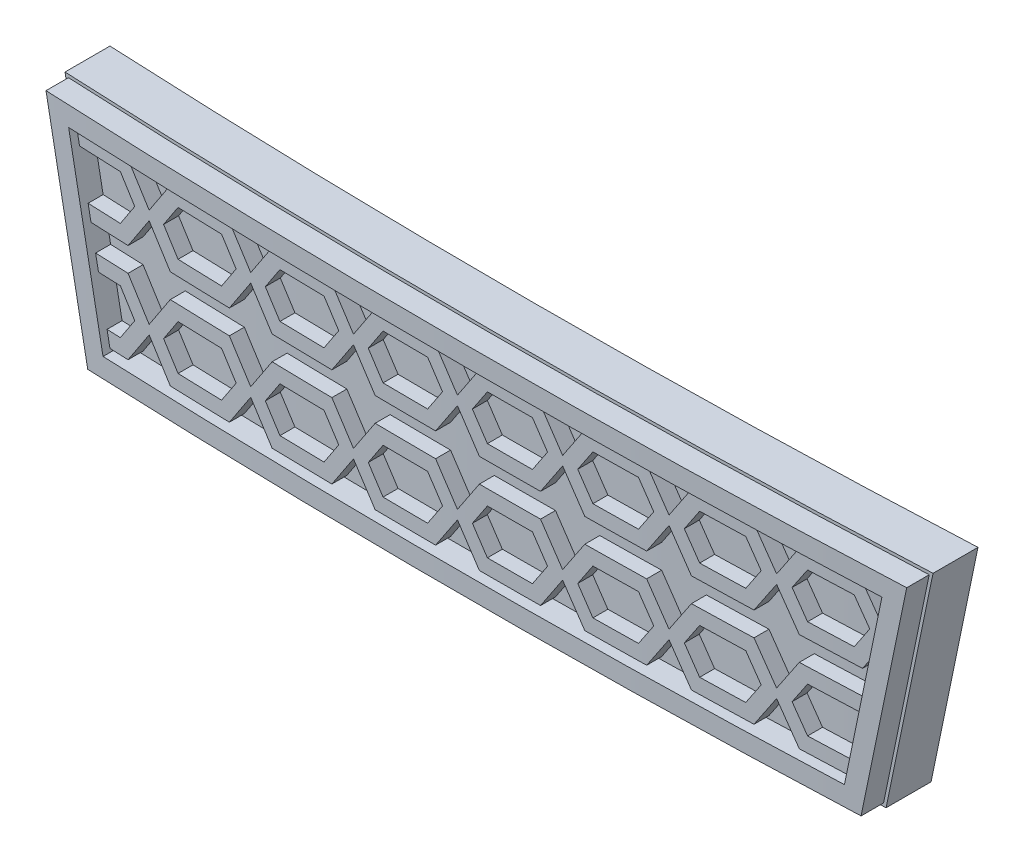
from build123d import *

# Parameters (mm, degrees)
BOSS_EXTRUDE1_DEPTH     = 25
SKETCH4_W               = 147
SKETCH4_H               = 25
CUT_EXTRUDE1_DEPTH      = 2.838054519
CUT_EXTRUDE1_DEPTH_BACK = 6.607602728
BOSS_EXTRUDE2_DEPTH     = 10
CUT_EXTRUDE2_DEPTH      = 16
CUT_EXTRUDE3_DEPTH      = 16
BOSS_EXTRUDE3_DEPTH     = 5
CUT_EXTRUDE4_DEPTH      = 16


with BuildPart() as part:
    # Sketch2 → Boss-Extrude1 (new body)
    with BuildSketch(Plane(origin=(0, 0, 0), x_dir=(1, 0, 0), z_dir=(0, 1, 0))):
        with BuildLine():
            Line((-73.115286629, 2.629690485), (-72.75191537, 5.607602728))
            ThreePointArc((-72.75191537, 5.607602728), (0.384713371, 1.161945481), (73.521342111, 5.607602728))
            Line((73.521342111, 5.607602728), (73.884713371, 2.629690485))
            ThreePointArc((73.884713371, 2.629690485), (0.384713371, -1.838054519), (-73.115286629, 2.629690485))
        make_face()
    extrude(amount=BOSS_EXTRUDE1_DEPTH)

    # Sketch4 → Cut-Extrude1 (cut, two sides)
    with BuildSketch(Plane.XY) as cut_extrude1_sk:
        with Locations((0.384713371, 12.5)):
            Rectangle(SKETCH4_W, SKETCH4_H)
        Polygon((-28.688823942, 19.998171544), (-25.688823942, 4.998171544), (26.311176058, 4.998171544), (29.311176058, 19.998171544), align=None, mode=Mode.SUBTRACT)
    extrude(amount=CUT_EXTRUDE1_DEPTH, mode=Mode.SUBTRACT)
    extrude(cut_extrude1_sk.sketch, amount=-CUT_EXTRUDE1_DEPTH_BACK, mode=Mode.SUBTRACT)

    # Sketch6 → Boss-Extrude2 (add, symmetric)
    with BuildSketch(Plane.XY):
        Polygon((25.88409597, 10.511300376), (26.037942124, 11.280531145), (25.761837756, 11.694687697), (21.691470239, 11.694687697), (20.226653997, 9.497463335), (18.761837756, 11.694687697), (14.691470239, 11.694687697), (13.226653997, 9.497463335), (11.761837756, 11.694687697), (7.691470239, 11.694687697), (6.226653997, 9.497463335), (4.761837756, 11.694687697), (0.691470239, 11.694687697), (-0.773346003, 9.497463335), (-2.238162244, 11.694687697), (-6.308529761, 11.694687697), (-7.773346003, 9.497463335), (-9.238162244, 11.694687697), (-13.308529761, 11.694687697), (-14.773346003, 9.497463335), (-16.238162244, 11.694687697), (-20.308529761, 11.694687697), (-21.773346003, 9.497463335), (-23.238162244, 11.694687697), (-25.498421319, 11.694687697), (-25.298421319, 10.694687697), (-23.773346003, 10.694687697), (-22.773346003, 9.194687697), (-23.773346003, 7.694687697), (-24.498421319, 7.694687697), (-24.698421319, 7.694687697), (-24.498421319, 6.694687697), (-23.238162244, 6.694687697), (-21.773346003, 8.89191206), (-20.308529761, 6.694687697), (-16.238162244, 6.694687697), (-14.773346003, 8.89191206), (-13.308529761, 6.694687697), (-9.238162244, 6.694687697), (-7.773346003, 8.89191206), (-6.308529761, 6.694687697), (-2.238162244, 6.694687697), (-0.773346003, 8.89191206), (0.691470239, 6.694687697), (4.761837756, 6.694687697), (6.226653997, 8.89191206), (7.691470239, 6.694687697), (11.761837756, 6.694687697), (13.226653997, 8.89191206), (14.691470239, 6.694687697), (18.761837756, 6.694687697), (20.226653997, 8.89191206), (21.691470239, 6.694687697), (25.120773434, 6.694687697), (25.370773434, 7.944687697), (25.120773434, 7.694687697), (22.226653997, 7.694687697), (21.226653997, 9.194687697), (22.226653997, 10.694687697), (25.761837756, 10.694687697), align=None)
        Polygon((18.226653997, 10.694687697), (19.226653997, 9.194687697), (18.226653997, 7.694687697), (15.226653997, 7.694687697), (14.226653997, 9.194687697), (15.226653997, 10.694687697), align=None, mode=Mode.SUBTRACT)
        Polygon((11.226653997, 10.694687697), (12.226653997, 9.194687697), (11.226653997, 7.694687697), (8.226653997, 7.694687697), (7.226653997, 9.194687697), (8.226653997, 10.694687697), align=None, mode=Mode.SUBTRACT)
        Polygon((4.226653997, 10.694687697), (5.226653997, 9.194687697), (4.226653997, 7.694687697), (1.226653997, 7.694687697), (0.226653997, 9.194687697), (1.226653997, 10.694687697), align=None, mode=Mode.SUBTRACT)
        Polygon((-2.773346003, 10.694687697), (-1.773346003, 9.194687697), (-2.773346003, 7.694687697), (-5.773346003, 7.694687697), (-6.773346003, 9.194687697), (-5.773346003, 10.694687697), align=None, mode=Mode.SUBTRACT)
        Polygon((-9.773346003, 10.694687697), (-8.773346003, 9.194687697), (-9.773346003, 7.694687697), (-12.773346003, 7.694687697), (-13.773346003, 9.194687697), (-12.773346003, 10.694687697), align=None, mode=Mode.SUBTRACT)
        Polygon((-16.773346003, 10.694687697), (-15.773346003, 9.194687697), (-16.773346003, 7.694687697), (-19.773346003, 7.694687697), (-20.773346003, 9.194687697), (-19.773346003, 10.694687697), align=None, mode=Mode.SUBTRACT)
        Polygon((-26.819814858, 18.30165539), (-26.619814858, 17.30165539), (-23.773346003, 17.30165539), (-22.773346003, 15.80165539), (-23.773346003, 14.30165539), (-25.819814858, 14.30165539), (-26.019814858, 14.30165539), (-25.819814858, 13.30165539), (-23.238162244, 13.30165539), (-21.773346003, 15.498879753), (-20.308529761, 13.30165539), (-16.238162244, 13.30165539), (-14.773346003, 15.498879753), (-13.308529761, 13.30165539), (-9.238162244, 13.30165539), (-7.773346003, 15.498879753), (-6.308529761, 13.30165539), (-2.238162244, 13.30165539), (-0.773346003, 15.498879753), (0.691470239, 13.30165539), (4.761837756, 13.30165539), (6.226653997, 15.498879753), (7.691470239, 13.30165539), (11.761837756, 13.30165539), (13.226653997, 15.498879753), (14.691470239, 13.30165539), (18.761837756, 13.30165539), (20.226653997, 15.498879753), (21.691470239, 13.30165539), (25.761837756, 13.30165539), (26.733736637, 14.759503713), (27.054398692, 16.362813986), (25.761837756, 18.30165539), (21.691470239, 18.30165539), (20.226653997, 16.104431028), (18.761837756, 18.30165539), (14.691470239, 18.30165539), (13.226653997, 16.104431028), (11.761837756, 18.30165539), (7.691470239, 18.30165539), (6.226653997, 16.104431028), (4.761837756, 18.30165539), (0.691470239, 18.30165539), (-0.773346003, 16.104431028), (-2.238162244, 18.30165539), (-6.308529761, 18.30165539), (-7.773346003, 16.104431028), (-9.238162244, 18.30165539), (-13.308529761, 18.30165539), (-14.773346003, 16.104431028), (-16.238162244, 18.30165539), (-20.308529761, 18.30165539), (-21.773346003, 16.104431028), (-23.238162244, 18.30165539), align=None)
        Polygon((-19.773346003, 17.30165539), (-16.773346003, 17.30165539), (-15.773346003, 15.80165539), (-16.773346003, 14.30165539), (-19.773346003, 14.30165539), (-20.773346003, 15.80165539), align=None, mode=Mode.SUBTRACT)
        Polygon((-12.773346003, 17.30165539), (-9.773346003, 17.30165539), (-8.773346003, 15.80165539), (-9.773346003, 14.30165539), (-12.773346003, 14.30165539), (-13.773346003, 15.80165539), align=None, mode=Mode.SUBTRACT)
        Polygon((-5.773346003, 17.30165539), (-2.773346003, 17.30165539), (-1.773346003, 15.80165539), (-2.773346003, 14.30165539), (-5.773346003, 14.30165539), (-6.773346003, 15.80165539), align=None, mode=Mode.SUBTRACT)
        Polygon((1.226653997, 17.30165539), (4.226653997, 17.30165539), (5.226653997, 15.80165539), (4.226653997, 14.30165539), (1.226653997, 14.30165539), (0.226653997, 15.80165539), align=None, mode=Mode.SUBTRACT)
        Polygon((8.226653997, 17.30165539), (11.226653997, 17.30165539), (12.226653997, 15.80165539), (11.226653997, 14.30165539), (8.226653997, 14.30165539), (7.226653997, 15.80165539), align=None, mode=Mode.SUBTRACT)
        Polygon((15.226653997, 17.30165539), (18.226653997, 17.30165539), (19.226653997, 15.80165539), (18.226653997, 14.30165539), (15.226653997, 14.30165539), (14.226653997, 15.80165539), align=None, mode=Mode.SUBTRACT)
        Polygon((22.226653997, 17.30165539), (25.226653997, 17.30165539), (26.222348398, 15.80811379), (25.901686343, 15.314203909), (25.226653997, 14.30165539), (22.226653997, 14.30165539), (21.226653997, 15.80165539), align=None, mode=Mode.SUBTRACT)
    extrude(amount=BOSS_EXTRUDE2_DEPTH, both=True)

    # Sketch7 → Cut-Extrude2 (cut, through all)
    with BuildSketch(Plane(origin=(0, 19.998171544, 0), x_dir=(1, 0, 0), z_dir=(0, 1, 0))):
        with BuildLine():
            Line((-28.688823942, 1.862290541), (-28.688823942, 14.063402661))
            Line((-28.688823942, 14.063402661), (29.311176058, 14.063402661))
            Line((29.311176058, 14.063402661), (29.311176058, 1.855218714))
            ThreePointArc((29.311176058, 1.855218714), (0.311091098, 1.16194997), (-28.688823942, 1.862290541))
        make_face()
    extrude(amount=-CUT_EXTRUDE2_DEPTH, mode=Mode.SUBTRACT)

    # Sketch8 → Cut-Extrude3 (cut, through all)
    with BuildSketch(Plane(origin=(0, 19.998171544, 0), x_dir=(1, 0, 0), z_dir=(0, 1, 0))):
        with BuildLine():
            Line((-28.736735452, -2.140027419), (-29.250227823, -12.845235251))
            Line((-29.250227823, -12.845235251), (31.174185646, -11.779155506))
            Line((31.174185646, -11.779155506), (29.358845197, -2.147075799))
            ThreePointArc((29.358845197, -2.147075799), (0.310970613, -2.838050045), (-28.736735452, -2.140027419))
        make_face()
    extrude(amount=-CUT_EXTRUDE3_DEPTH, mode=Mode.SUBTRACT)

    # Sketch9 → Boss-Extrude3 (add, symmetric)
    with BuildSketch(Plane.XY):
        Polygon((-25.524863162, 5.198171544), (26.147215277, 5.198171544), (29.067215277, 19.798171544), (-28.444863162, 19.798171544), align=None)
        Polygon((27.481470203, 18.498171544), (-26.859118088, 18.498171544), (-24.459118088, 6.498171544), (25.081470203, 6.498171544), align=None, mode=Mode.SUBTRACT)
    extrude(amount=BOSS_EXTRUDE3_DEPTH, both=True)

    # Sketch11 → Cut-Extrude4 (cut, through all)
    with BuildSketch(Plane(origin=(0, 19.998171544, 0), x_dir=(1, 0, 0), z_dir=(0, 1, 0))):
        with BuildLine():
            Line((-28.688823942, 1.862290541), (-28.688823942, 6.065870335))
            Line((-28.688823942, 6.065870335), (29.311176058, 6.065870335))
            Line((29.311176058, 6.065870335), (29.311176058, 1.855218714))
            ThreePointArc((29.311176058, 1.855218714), (0.311091098, 1.16194997), (-28.688823942, 1.862290541))
        make_face()
        with BuildLine():
            Line((-28.760691207, -2.639453211), (-28.942662581, -6.433163682))
            Line((-28.942662581, -6.433163682), (29.382679766, -6.433163682))
            Line((29.382679766, -6.433163682), (29.382679766, -2.646507389))
            ThreePointArc((29.382679766, -2.646507389), (0.310909951, -3.338050041), (-28.760691207, -2.639453211))
        make_face()
    extrude(amount=-CUT_EXTRUDE4_DEPTH, mode=Mode.SUBTRACT)


solid = part.part
